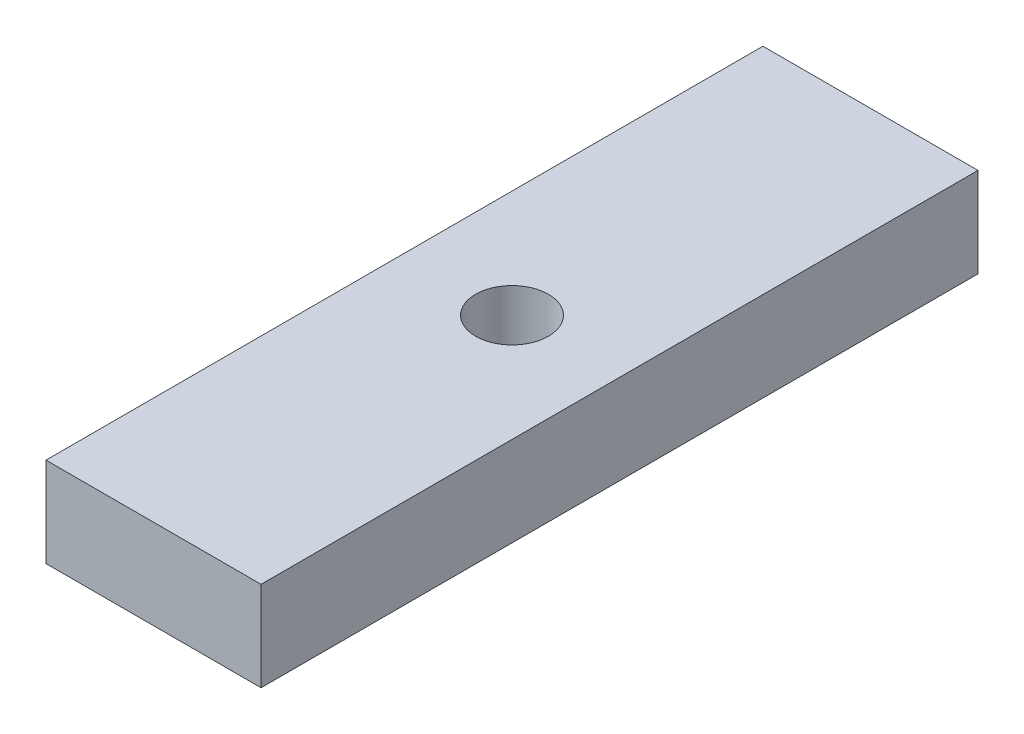
from build123d import *

# Parameters (mm, degrees)
SKETCH1_W                 = 76.2
SKETCH1_H                 = 31.75
BOSS_EXTRUDE1_DEPTH       = 127
F_1_CLEARANCE_HOLE1_D     = 25.79624
F_1_CLEARANCE_HOLE1_DEPTH = 24.003
F_1_CLEARANCE_HOLE1_TIP   = 7.749972367


with BuildPart() as part:
    # Sketch1 → Boss-Extrude1 (new body, symmetric)
    with BuildSketch(Plane.XY):
        Rectangle(SKETCH1_W, SKETCH1_H)
    extrude(amount=BOSS_EXTRUDE1_DEPTH, both=True)

    # 1 Clearance Hole1
    with Locations(Plane(origin=(0, 15.875, 0), x_dir=(-1, 0, 0), z_dir=(0, 1, 0))):
        with Locations((0, 0)):
            Hole(F_1_CLEARANCE_HOLE1_D / 2, depth=F_1_CLEARANCE_HOLE1_DEPTH)
            with Locations((0, 0, -(F_1_CLEARANCE_HOLE1_DEPTH + F_1_CLEARANCE_HOLE1_TIP / 2))):  # 118° drill point
                Cone(0, F_1_CLEARANCE_HOLE1_D / 2, F_1_CLEARANCE_HOLE1_TIP, mode=Mode.SUBTRACT)


solid = part.part
